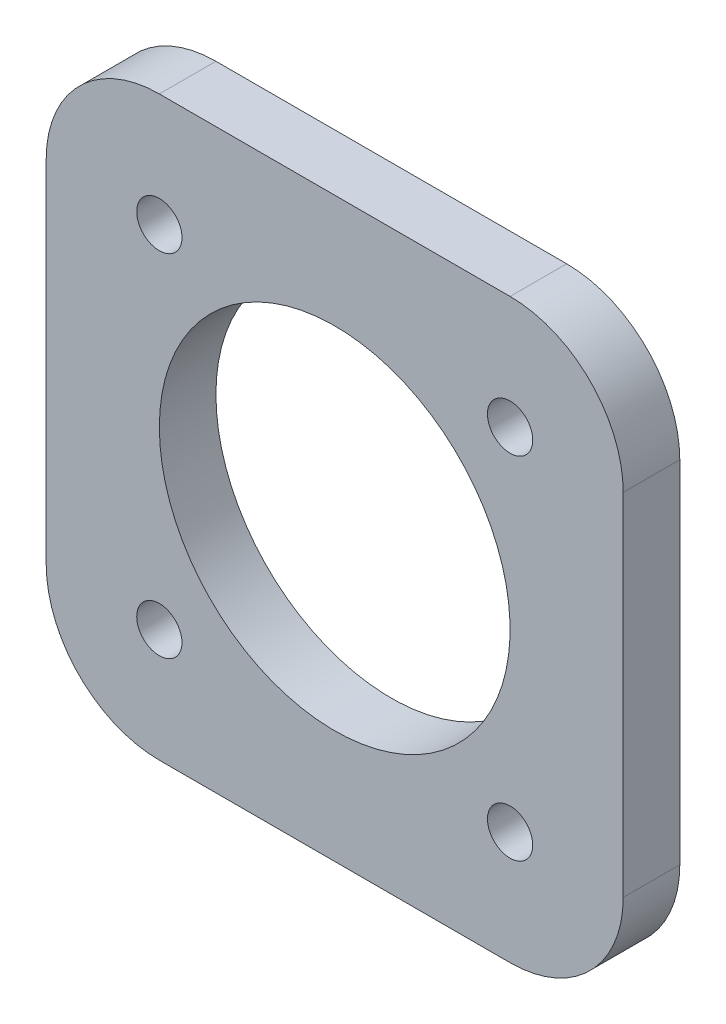
from build123d import *

# Parameters (mm, degrees)
SKETCH_1_R          = 2
EXTRUDE_1_DEPTH     = 5
SKETCH_2_R          = 15.5
CUT_EXTRUDE_1_DEPTH = 30


with BuildPart() as part:
    # 草图1 → 凸台-拉伸1 (new body)
    with BuildSketch(Plane.XY):
        with BuildLine():
            Line((-15.5, -25.5), (15.5, -25.5))
            ThreePointArc((15.5, -25.5), (22.571067812, -22.571067812), (25.5, -15.5))
            Line((25.5, -15.5), (25.5, 15.5))
            ThreePointArc((25.5, 15.5), (22.571067812, 22.571067812), (15.5, 25.5))
            Line((15.5, 25.5), (-15.5, 25.5))
            ThreePointArc((-15.5, 25.5), (-22.571067812, 22.571067812), (-25.5, 15.5))
            Line((-25.5, 15.5), (-25.5, -15.5))
            ThreePointArc((-25.5, -15.5), (-22.571067812, -22.571067812), (-15.5, -25.5))
        make_face()
        with Locations((-15.5, 15.5)):
            Circle(SKETCH_1_R, mode=Mode.SUBTRACT)
        with Locations((15.5, 15.5)):
            Circle(SKETCH_1_R, mode=Mode.SUBTRACT)
        with Locations((15.5, -15.5)):
            Circle(SKETCH_1_R, mode=Mode.SUBTRACT)
        with Locations((-15.5, -15.5)):
            Circle(SKETCH_1_R, mode=Mode.SUBTRACT)
    extrude(amount=EXTRUDE_1_DEPTH)

    # 草图2 → 切除-拉伸1 (cut)
    with BuildSketch(Plane.XY):
        Circle(SKETCH_2_R)
    extrude(amount=CUT_EXTRUDE_1_DEPTH, mode=Mode.SUBTRACT)


solid = part.part
